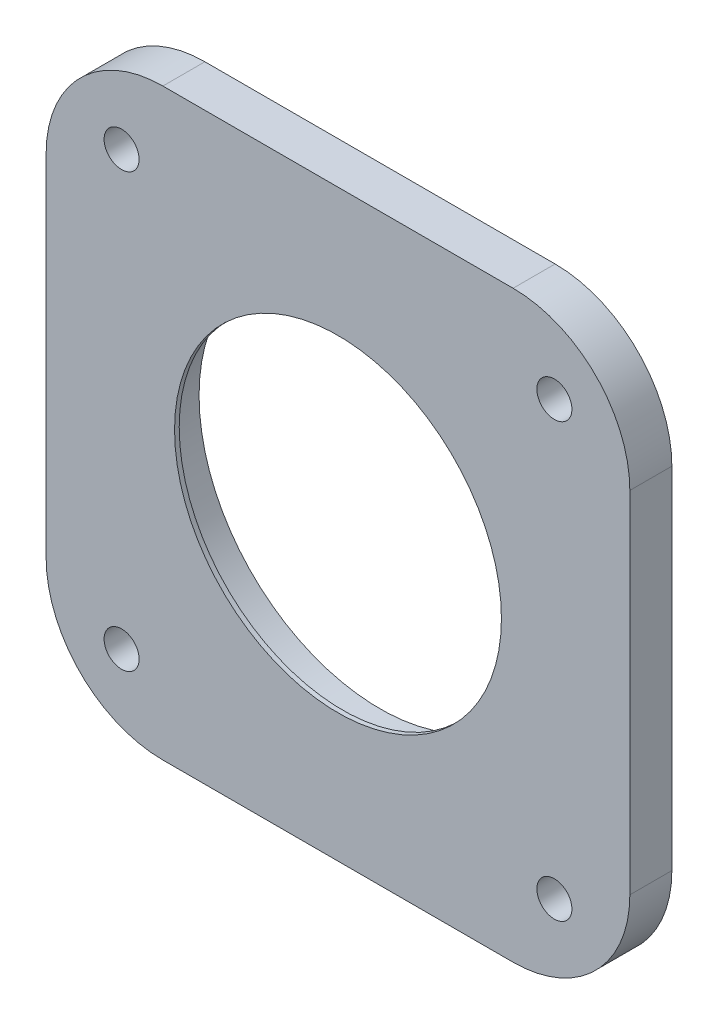
from build123d import *

# Parameters (mm, degrees)
SKETCH1_R           = 19.685
SKETCH1_R_2         = 1.905
BOSS_EXTRUDE1_DEPTH = 4.572
SKETCH2_R           = 19.685
SKETCH2_R_2         = 17.78
BOSS_EXTRUDE2_DEPTH = 0.508


with BuildPart() as part:
    # Sketch1 → Boss-Extrude1 (new body)
    with BuildSketch(Plane.XY):
        with BuildLine():
            Line((-19.05, -31.75), (19.05, -31.75))
            ThreePointArc((19.05, -31.75), (28.030256121, -28.030256121), (31.75, -19.05))
            Line((31.75, -19.05), (31.75, 19.05))
            ThreePointArc((31.75, 19.05), (28.030256121, 28.030256121), (19.05, 31.75))
            Line((19.05, 31.75), (-19.05, 31.75))
            ThreePointArc((-19.05, 31.75), (-28.030256121, 28.030256121), (-31.75, 19.05))
            Line((-31.75, 19.05), (-31.75, -19.05))
            ThreePointArc((-31.75, -19.05), (-28.030256121, -28.030256121), (-19.05, -31.75))
        make_face()
        Circle(SKETCH1_R, mode=Mode.SUBTRACT)
        with Locations((-23.540128061, 23.540128061)):
            Circle(SKETCH1_R_2, mode=Mode.SUBTRACT)
        with Locations((23.540128061, 23.540128061)):
            Circle(SKETCH1_R_2, mode=Mode.SUBTRACT)
        with Locations((23.540128061, -23.540128061)):
            Circle(SKETCH1_R_2, mode=Mode.SUBTRACT)
        with Locations((-23.540128061, -23.540128061)):
            Circle(SKETCH1_R_2, mode=Mode.SUBTRACT)
    extrude(amount=BOSS_EXTRUDE1_DEPTH)

    # Sketch2 → Boss-Extrude2 (add)
    with BuildSketch(Plane.XY.offset(4.572)):
        Circle(SKETCH2_R)
        Circle(SKETCH2_R_2, mode=Mode.SUBTRACT)
    extrude(amount=-BOSS_EXTRUDE2_DEPTH)


solid = part.part
